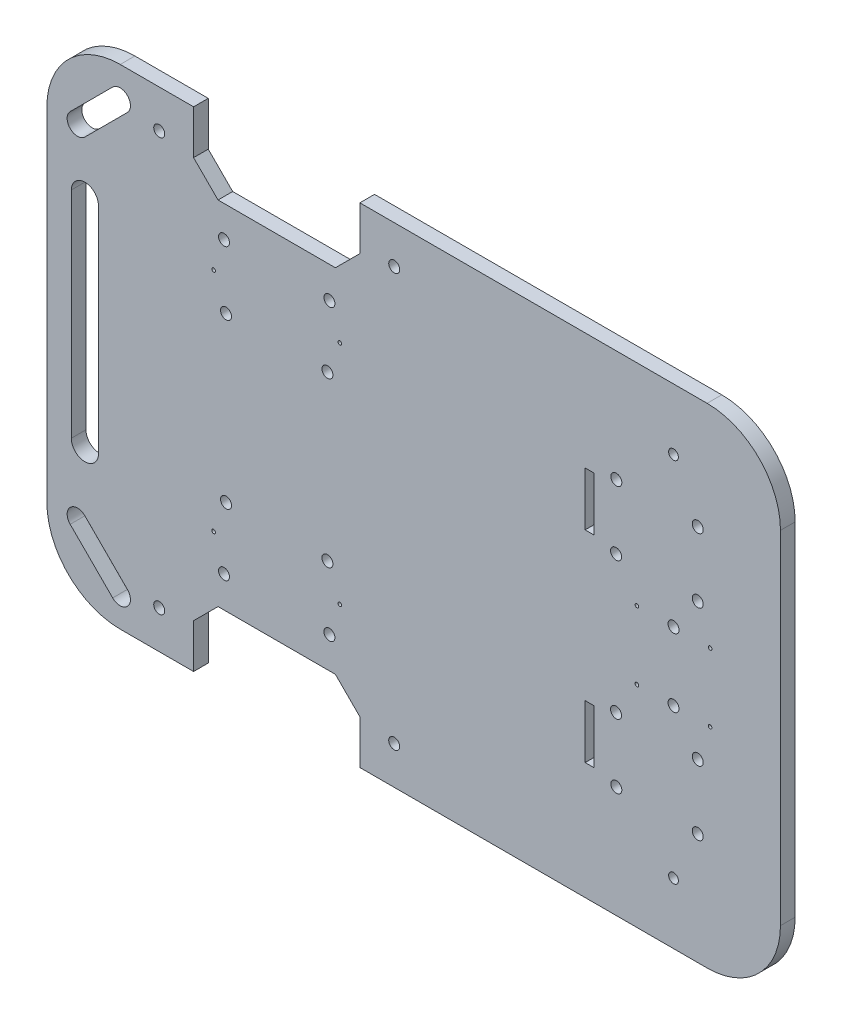
from build123d import *

# Parameters (mm, degrees)
SKETCH2_R           = 2.25
SKETCH2_R_2         = 2
BOSS_EXTRUDE2_DEPTH = 6
SKETCH5_R           = 2.25
CUT_EXTRUDE2_DEPTH  = 7
SKETCH6_R           = 0.75
SKETCH6_W           = 3.570647065
SKETCH6_H           = 21.947745834
CUT_EXTRUDE3_DEPTH  = 7
SKETCH7_R           = 0.75
CUT_EXTRUDE4_DEPTH  = 7


with BuildPart() as part:
    # Sketch2 → Boss-Extrude2 (new body)
    with BuildSketch(Plane.XY):
        with BuildLine():
            ThreePointArc((0, 30), (8.786796564, 8.786796564), (30, 0))
            Line((30, 0), (60, 0))
            Line((60, 0), (60, 18))
            Line((60, 18), (70, 28))
            Line((70, 28), (118, 28))
            Line((118, 28), (128, 18))
            Line((128, 18), (128, 0))
            Line((128, 0), (270, 0))
            ThreePointArc((270, 0), (291.213203436, 8.786796564), (300, 30))
            Line((300, 30), (300, 170))
            ThreePointArc((300, 170), (291.213203436, 191.213203436), (270, 200))
            Line((270, 200), (128, 200))
            Line((128, 200), (128, 182))
            Line((128, 182), (118, 172))
            Line((118, 172), (70, 172))
            Line((70, 172), (60, 182))
            Line((60, 182), (60, 200))
            Line((60, 200), (30, 200))
            ThreePointArc((30, 200), (8.786796564, 191.213203436), (0, 170))
            Line((0, 170), (0, 30))
        make_face()
        with BuildLine():
            Line((26.918743033, 9.536510288), (9.536510288, 26.918743033))
            ThreePointArc((9.536510288, 26.918743033), (9.536510288, 32.929150673), (15.546917928, 32.929150673))
            Line((15.546917928, 32.929150673), (32.929150673, 15.546917928))
            ThreePointArc((32.929150673, 15.546917928), (32.929150673, 9.536510288), (26.918743033, 9.536510288))
        make_face(mode=Mode.SUBTRACT)
        with Locations((45.951664231, 15.546917928)):
            Circle(SKETCH2_R, mode=Mode.SUBTRACT)
        with Locations((142.048335769, 15.546917928)):
            Circle(SKETCH2_R, mode=Mode.SUBTRACT)
        with Locations((256.262155689, 25)):
            Circle(SKETCH2_R_2, mode=Mode.SUBTRACT)
        with Locations((232.877141624, 45.572368642)):
            Circle(SKETCH2_R, mode=Mode.SUBTRACT)
        with Locations((266.174553403, 45.645)):
            Circle(SKETCH2_R, mode=Mode.SUBTRACT)
        with Locations((232.771355194, 71.922156293)):
            Circle(SKETCH2_R, mode=Mode.SUBTRACT)
        with Locations((266.174553403, 71.995)):
            Circle(SKETCH2_R, mode=Mode.SUBTRACT)
        with Locations((256.262155689, 86.035)):
            Circle(SKETCH2_R, mode=Mode.SUBTRACT)
        with BuildLine():
            ThreePointArc((9.996523571, 145.539520474), (15.546917928, 151.089914831), (21.097312286, 145.539520474))
            Line((21.097312286, 145.539520474), (21.097312286, 57.620027261))
            ThreePointArc((21.097312286, 57.620027261), (15.546917928, 52.069632903), (9.996523571, 57.620027261))
            Line((9.996523571, 57.620027261), (9.996523571, 145.539520474))
        make_face(mode=Mode.SUBTRACT)
        with BuildLine():
            ThreePointArc((15.546917928, 167.070849327), (9.536510288, 167.070849327), (9.536510288, 173.081256967))
            Line((9.536510288, 173.081256967), (26.918743033, 190.463489712))
            ThreePointArc((26.918743033, 190.463489712), (32.929150673, 190.463489712), (32.929150673, 184.453082072))
            Line((32.929150673, 184.453082072), (15.546917928, 167.070849327))
        make_face(mode=Mode.SUBTRACT)
        with Locations((45.951664231, 184.453082072)):
            Circle(SKETCH2_R, mode=Mode.SUBTRACT)
        with Locations((142.048335769, 184.453082072)):
            Circle(SKETCH2_R, mode=Mode.SUBTRACT)
        with Locations((256.262155689, 113.965)):
            Circle(SKETCH2_R, mode=Mode.SUBTRACT)
        with Locations((232.771355194, 128.077843707)):
            Circle(SKETCH2_R, mode=Mode.SUBTRACT)
        with Locations((266.174553403, 128.005)):
            Circle(SKETCH2_R, mode=Mode.SUBTRACT)
        with Locations((232.877141624, 154.427631358)):
            Circle(SKETCH2_R, mode=Mode.SUBTRACT)
        with Locations((266.174553403, 154.355)):
            Circle(SKETCH2_R, mode=Mode.SUBTRACT)
        with Locations((256.262155689, 175)):
            Circle(SKETCH2_R_2, mode=Mode.SUBTRACT)
    extrude(amount=BOSS_EXTRUDE2_DEPTH)

    # Sketch5 → Cut-Extrude2 (cut, through all)
    with BuildSketch(Plane.XY.offset(6)):
        with Locations((73.27, 66.55)):
            Circle(SKETCH5_R)
        with Locations((72.45, 40.85)):
            Circle(SKETCH5_R)
        with Locations((115.55, 40.85)):
            Circle(SKETCH5_R)
        with Locations((114.73, 66.55)):
            Circle(SKETCH5_R)
        with Locations((115.55, 159.15)):
            Circle(SKETCH5_R)
        with Locations((72.45, 159.15)):
            Circle(SKETCH5_R)
        with Locations((73.27, 133.45)):
            Circle(SKETCH5_R)
        with Locations((114.73, 133.45)):
            Circle(SKETCH5_R)
    extrude(amount=-CUT_EXTRUDE2_DEPTH, mode=Mode.SUBTRACT)

    # Sketch6 → Cut-Extrude3 (cut, through all)
    with BuildSketch(Plane.XY.offset(6)):
        with Locations((68.18, 146.3)):
            Circle(SKETCH6_R)
        with Locations((119.82, 146.3)):
            Circle(SKETCH6_R)
        with Locations((119.82, 53.7)):
            Circle(SKETCH6_R)
        with Locations((68.18, 53.7)):
            Circle(SKETCH6_R)
        with Locations((221.907735921, 58.796241559)):
            Rectangle(SKETCH6_W, SKETCH6_H)
        with Locations((221.907735921, 141.203758441)):
            Rectangle(SKETCH6_W, SKETCH6_H)
    extrude(amount=-CUT_EXTRUDE3_DEPTH, mode=Mode.SUBTRACT)

    # Sketch7 → Cut-Extrude4 (cut, through all)
    with BuildSketch(Plane.XY.offset(6)):
        with Locations((241.292155689, 113.965)):
            Circle(SKETCH7_R)
        with Locations((241.292155689, 86.035)):
            Circle(SKETCH7_R)
        with Locations((271.232155689, 86.035)):
            Circle(SKETCH7_R)
        with Locations((271.232155689, 113.965)):
            Circle(SKETCH7_R)
    extrude(amount=-CUT_EXTRUDE4_DEPTH, mode=Mode.SUBTRACT)


solid = part.part
